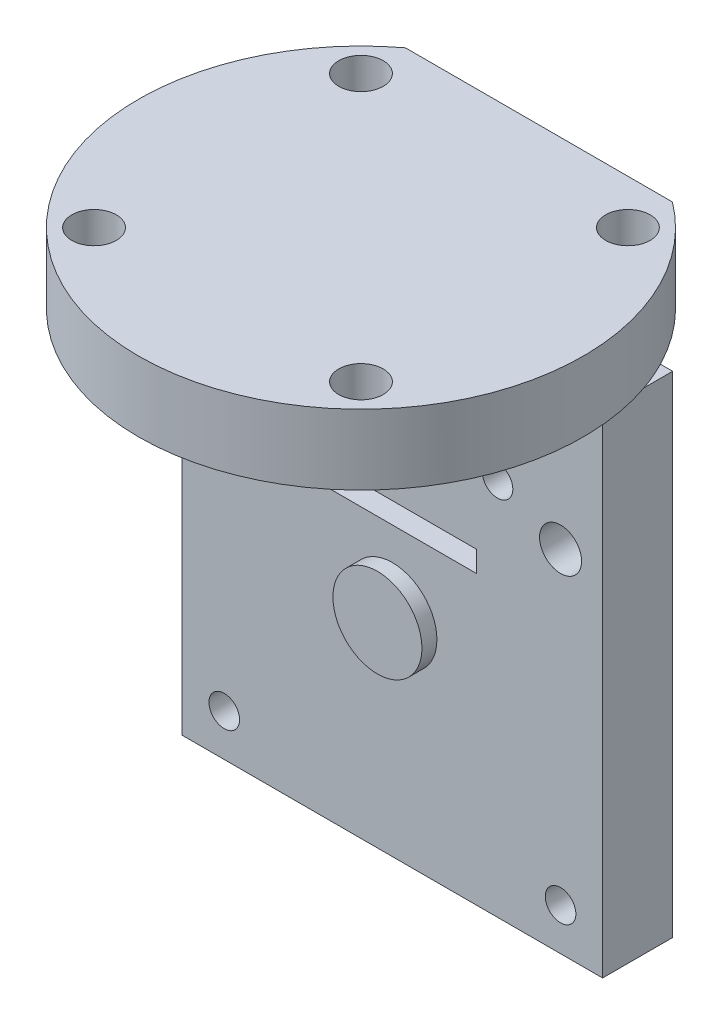
from build123d import *

# Parameters (mm, degrees)
SKETCH1_R            = 1.5875
BOSS_EXTRUDE3_DEPTH  = 5
SKETCH2_R            = 1.5875
BOSS_EXTRUDE4_DEPTH  = 5
BOSS_EXTRUDE9_START  = -2.245
SKETCH3_W            = 30
SKETCH3_H            = 35
SKETCH3_R            = 1.0922
SKETCH3_R_2          = 3.175
SKETCH3_W_2          = 12
SKETCH3_H_2          = 1.5
BOSS_EXTRUDE9_DEPTH  = 5
SKETCH11_R           = 3.175
BOSS_EXTRUDE10_DEPTH = 6.07
SKETCH12_R           = 1.5
CUT_EXTRUDE2_DEPTH   = 5


with BuildPart() as part:
    # Sketch1 → Boss-Extrude3 (new body)
    with BuildSketch(Plane(origin=(0, 0, 0), x_dir=(1, 0, 0), z_dir=(0, 1, 0))):
        with BuildLine():
            Line((9.525, 12.7), (-9.525, 12.7))
            ThreePointArc((-9.525, 12.7), (0, -15.875), (9.525, 12.7))
        make_face()
        with Locations((-12.7, 0)):
            Circle(SKETCH1_R, mode=Mode.SUBTRACT)
        with Locations((12.7, 0)):
            Circle(SKETCH1_R, mode=Mode.SUBTRACT)
        with Locations((0, -12.7)):
            Circle(SKETCH1_R, mode=Mode.SUBTRACT)
        with Locations((9.525, 9.525)):
            Circle(SKETCH1_R, mode=Mode.SUBTRACT)
        with Locations((-9.525, 9.525)):
            Circle(SKETCH1_R, mode=Mode.SUBTRACT)
        with Locations((-9.525, -9.525)):
            Circle(SKETCH1_R, mode=Mode.SUBTRACT)
        with Locations((9.525, -9.525)):
            Circle(SKETCH1_R, mode=Mode.SUBTRACT)
    extrude(amount=BOSS_EXTRUDE3_DEPTH)

    # Sketch2 → Boss-Extrude4 (add)
    with BuildSketch(Plane(origin=(0, 0, 0), x_dir=(1, 0, 0), z_dir=(0, 1, 0))):
        with Locations((-12.7, 0)):
            Circle(SKETCH2_R)
        with Locations((0, -12.7)):
            Circle(SKETCH2_R)
        with Locations((12.7, 0)):
            Circle(SKETCH2_R)
    extrude(amount=BOSS_EXTRUDE4_DEPTH)

    # Sketch3 → Boss-Extrude9 (add)
    with BuildSketch(Plane.XY.offset(BOSS_EXTRUDE9_START)):
        with Locations((0, -17.5)):
            Rectangle(SKETCH3_W, SKETCH3_H)
        with Locations((-7.5, -8)):
            Circle(SKETCH3_R, mode=Mode.SUBTRACT)
        with Locations((7.5, -8)):
            Circle(SKETCH3_R, mode=Mode.SUBTRACT)
        with Locations((0, -20)):
            Circle(SKETCH3_R_2, mode=Mode.SUBTRACT)
        with Locations((-12, -32)):
            Circle(SKETCH3_R, mode=Mode.SUBTRACT)
        with Locations((12, -32)):
            Circle(SKETCH3_R, mode=Mode.SUBTRACT)
        with Locations((0, -13.75)):
            Rectangle(SKETCH3_W_2, SKETCH3_H_2, mode=Mode.SUBTRACT)
    extrude(amount=-BOSS_EXTRUDE9_DEPTH)

    # Sketch11 → Boss-Extrude10 (add)
    with BuildSketch(Plane(origin=(0, 0, -7.245), x_dir=(-1, 0, 0), z_dir=(0, 0, -1))):
        with Locations((0, -20)):
            Circle(SKETCH11_R)
    extrude(amount=-BOSS_EXTRUDE10_DEPTH)

    # Sketch12 → Cut-Extrude2 (cut)
    with BuildSketch(Plane(origin=(0, 0, -7.245), x_dir=(-1, 0, 0), z_dir=(0, 0, -1))):
        with Locations((-12, -10)):
            Circle(SKETCH12_R)
        with Locations((0, -10)):
            Circle(SKETCH12_R)
        with Locations((12, -10)):
            Circle(SKETCH12_R)
    extrude(amount=-CUT_EXTRUDE2_DEPTH, mode=Mode.SUBTRACT)


solid = part.part
